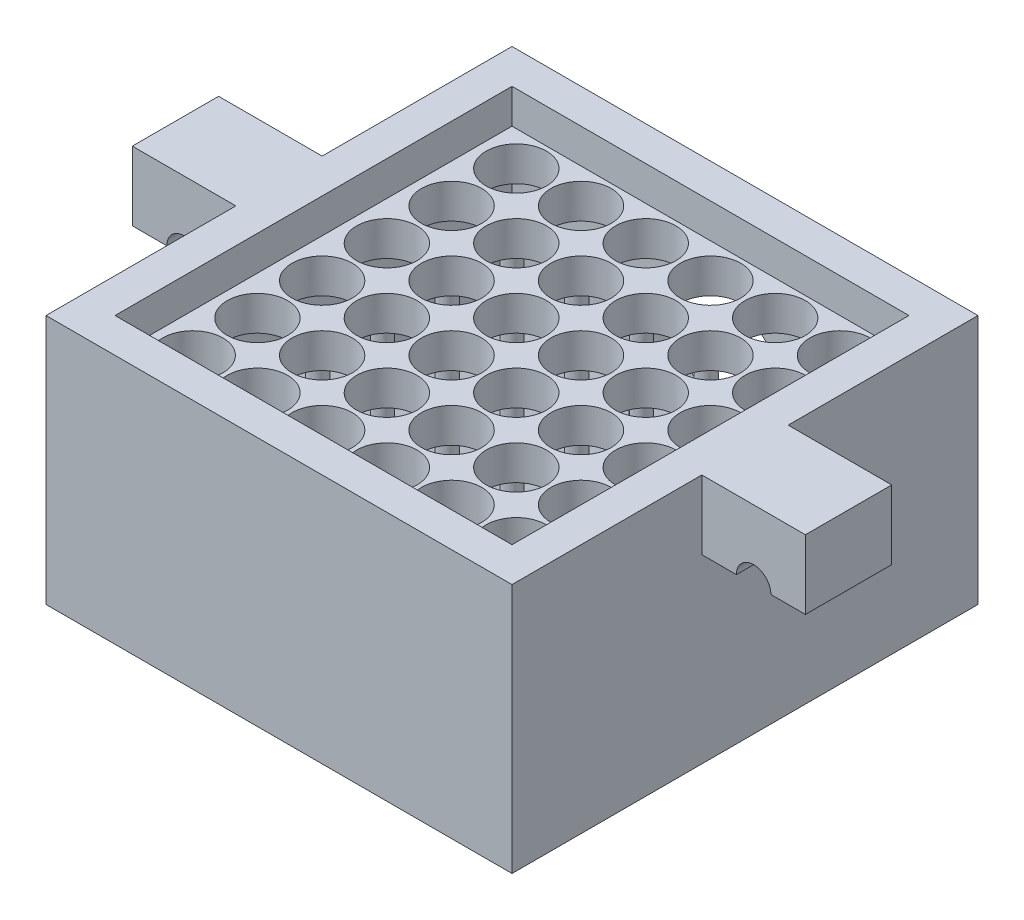
from build123d import *

# Parameters (mm, degrees)
SKETCH1_W            = 27
SKETCH1_H            = 27
SKETCH1_W_2          = 23
SKETCH1_H_2          = 23
BOSS_EXTRUDE1_DEPTH  = 2
SKETCH2_W            = 27
SKETCH2_H            = 27
BOSS_EXTRUDE2_DEPTH  = 2
SKETCH12_W           = 5
SKETCH12_H           = 4
BOSS_EXTRUDE9_DEPTH  = 6
SKETCH13_R           = 1.75
CUT_EXTRUDE4_DEPTH   = 2
LPATTERN3_COUNT      = 6
LPATTERN3_PITCH      = 3.75
LPATTERN3_COUNT_DIR2 = 6
LPATTERN3_PITCH_DIR2 = 3.75
CUT_EXTRUDE5_REACH   = 18
SKETCH14_W           = 27
SKETCH14_H           = 27
SKETCH14_W_2         = 23
SKETCH14_H_2         = 23
BOSS_EXTRUDE10_DEPTH = 8.5
BOSS_EXTRUDE11_DEPTH = 23
SKETCH18_W           = 27
SKETCH18_H           = 27
BOSS_EXTRUDE12_DEPTH = 2
SKETCH17_R           = 4.25
CUT_EXTRUDE10_DEPTH  = 2
SKETCH19_R           = 0.5
BOSS_EXTRUDE13_DEPTH = 6.51087


with BuildPart() as part:
    # Sketch1 → Boss-Extrude1 (new body)
    with BuildSketch(Plane(origin=(0, 0, 0), x_dir=(1, 0, 0), z_dir=(0, 1, 0))):
        Rectangle(SKETCH1_W, SKETCH1_H)
        Rectangle(SKETCH1_W_2, SKETCH1_H_2, mode=Mode.SUBTRACT)
    extrude(amount=BOSS_EXTRUDE1_DEPTH)

    # Sketch2 → Boss-Extrude2 (add)
    with BuildSketch(Plane.XZ):
        Rectangle(SKETCH2_W, SKETCH2_H)
    extrude(amount=BOSS_EXTRUDE2_DEPTH)

    # Sketch12 → Boss-Extrude9 (add)
    with BuildSketch(Plane.ZY.offset(13.5)):
        Rectangle(SKETCH12_W, SKETCH12_H)
    boss_extrude9 = extrude(amount=BOSS_EXTRUDE9_DEPTH)

    # Mirror1: Boss-Extrude9 across plane
    add(boss_extrude9.mirror(Plane(origin=(0, 0, 0), x_dir=(0, 0, 1), z_dir=(1, 0, 0))))

    # Sketch13 → Cut-Extrude4 (cut)
    with BuildSketch(Plane(origin=(0, 0, 0), x_dir=(1, 0, 0), z_dir=(0, 1, 0))):
        with Locations((9.5, 9.5)):
            Circle(SKETCH13_R)
    cut_extrude4 = extrude(amount=-CUT_EXTRUDE4_DEPTH, mode=Mode.SUBTRACT)

    # LPattern3: Cut-Extrude4 6 × 6
    with Locations(*[(-j * LPATTERN3_PITCH_DIR2, 0, i * LPATTERN3_PITCH) for i in range(LPATTERN3_COUNT) for j in range(LPATTERN3_COUNT_DIR2) if (i, j) != (0, 0)]):
        add(cut_extrude4, mode=Mode.SUBTRACT)

    # Sketch15 → Cut-Extrude5 (cut, up to next)
    with BuildSketch(Plane.XY.offset(2.5), mode=Mode.PRIVATE) as cut_extrude5_sk1:
        with BuildLine():
            Line((-17.5, -2), (-15.5, -2))
            ThreePointArc((-15.5, -2), (-16.5, -1), (-17.5, -2))
        make_face()
    cut_extrude5_tool1 = extrude(cut_extrude5_sk1.sketch, amount=-CUT_EXTRUDE5_REACH, mode=Mode.PRIVATE) & part.part
    add(cut_extrude5_tool1.solids().sort_by_distance((-16.5, -1.575587, 2.5))[0], mode=Mode.SUBTRACT)
    # Sketch15 → Cut-Extrude5 (cut, up to next)
    with BuildSketch(Plane.XY.offset(2.5), mode=Mode.PRIVATE) as cut_extrude5_sk2:
        with BuildLine():
            Line((17.5, -2), (15.5, -2))
            ThreePointArc((15.5, -2), (16.5, -1), (17.5, -2))
        make_face()
    cut_extrude5_tool2 = extrude(cut_extrude5_sk2.sketch, amount=-CUT_EXTRUDE5_REACH, mode=Mode.PRIVATE) & part.part
    add(cut_extrude5_tool2.solids().sort_by_distance((16.5, -1.575587, 2.5))[0], mode=Mode.SUBTRACT)

    # Sketch14 → Boss-Extrude10 (add)
    with BuildSketch(Plane.XZ.offset(2)):
        Rectangle(SKETCH14_W, SKETCH14_H)
        Rectangle(SKETCH14_W_2, SKETCH14_H_2, mode=Mode.SUBTRACT)
    extrude(amount=BOSS_EXTRUDE10_DEPTH)

    # Sketch16 → Boss-Extrude11 (add)
    with BuildSketch(Plane.ZY.offset(-11.5)):
        Polygon((11.5, -10.5), (-11.5, -10.5), (-11.5, -9.5), (11.5, -3), align=None)
    extrude(amount=BOSS_EXTRUDE11_DEPTH)

    # Sketch18 → Boss-Extrude12 (add)
    with BuildSketch(Plane.XZ.offset(10.5)):
        Rectangle(SKETCH18_W, SKETCH18_H)
    extrude(amount=BOSS_EXTRUDE12_DEPTH)

    # Sketch17 → Cut-Extrude10 (cut)
    with BuildSketch(Plane(origin=(0, 0, -13.5), x_dir=(-1, 0, 0), z_dir=(0, 0, -1))):
        with Locations((0, -6.25)):
            Circle(SKETCH17_R)
    extrude(amount=-CUT_EXTRUDE10_DEPTH, mode=Mode.SUBTRACT)

    # Sketch19 → Boss-Extrude13 (add)
    with BuildSketch(Plane.XZ.offset(2)):
        Circle(SKETCH19_R)
        with Locations((3.75, 0)):
            Circle(SKETCH19_R)
        with Locations((0, 3.75)):
            Circle(SKETCH19_R)
        with Locations((-3.75, 3.75)):
            Circle(SKETCH19_R)
        with Locations((3.75, 3.75)):
            Circle(SKETCH19_R)
        with Locations((7.5, 3.75)):
            Circle(SKETCH19_R)
        with Locations((7.5, 7.5)):
            Circle(SKETCH19_R)
        with Locations((3.75, 7.5)):
            Circle(SKETCH19_R)
        with Locations((0, 7.5)):
            Circle(SKETCH19_R)
        with Locations((-3.75, 7.5)):
            Circle(SKETCH19_R)
        with Locations((-7.5, 7.5)):
            Circle(SKETCH19_R)
        with Locations((-7.5, 3.75)):
            Circle(SKETCH19_R)
        with Locations((-7.5, 0)):
            Circle(SKETCH19_R)
        with Locations((-3.75, 0)):
            Circle(SKETCH19_R)
        with Locations((-3.75, -3.75)):
            Circle(SKETCH19_R)
        with Locations((-7.5, -3.75)):
            Circle(SKETCH19_R)
        with Locations((-7.5, -7.5)):
            Circle(SKETCH19_R)
        with Locations((-3.75, -7.5)):
            Circle(SKETCH19_R)
        with Locations((0, -7.5)):
            Circle(SKETCH19_R)
        with Locations((0, -3.75)):
            Circle(SKETCH19_R)
        with Locations((3.75, -3.75)):
            Circle(SKETCH19_R)
        with Locations((3.75, -7.5)):
            Circle(SKETCH19_R)
        with Locations((7.5, -7.5)):
            Circle(SKETCH19_R)
        with Locations((7.5, -3.75)):
            Circle(SKETCH19_R)
        with Locations((7.5, 0)):
            Circle(SKETCH19_R)
    extrude(amount=BOSS_EXTRUDE13_DEPTH)


solid = part.part
